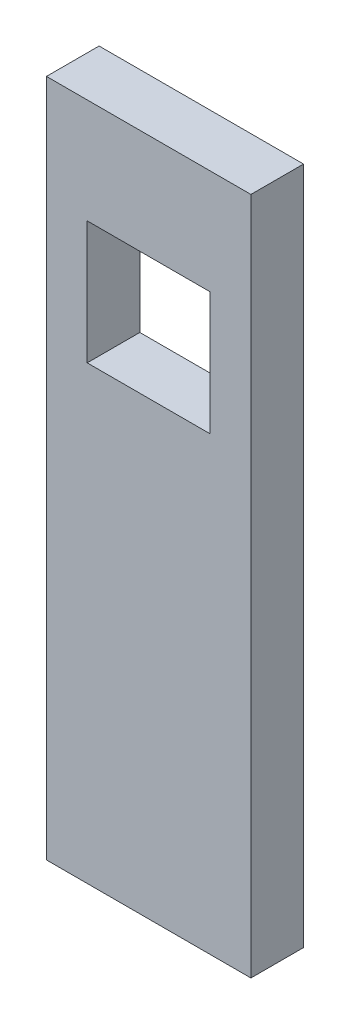
from build123d import *

# Parameters (mm, degrees)
SKETCH1_W           = 12.15
SKETCH1_H           = 12.15
BOSS_EXTRUDE1_DEPTH = 2.6


with BuildPart() as part:
    # Sketch1 → Boss-Extrude1 (new body, symmetric)
    with BuildSketch(Plane.XY):
        Polygon((-0.1, 66.95), (20.1, 66.95), (20.1, 44.55), (20.1, 39.4), (20.1, 27.45), (20.1, 22.3), (20.1, -0.1), (-0.1, -0.1), (-0.1, 22.3), (-0.1, 27.45), (-0.1, 39.4), (-0.1, 44.55), align=None)
        with Locations((10, 50.525)):
            Rectangle(SKETCH1_W, SKETCH1_H, mode=Mode.SUBTRACT)
    extrude(amount=BOSS_EXTRUDE1_DEPTH, both=True)


solid = part.part
